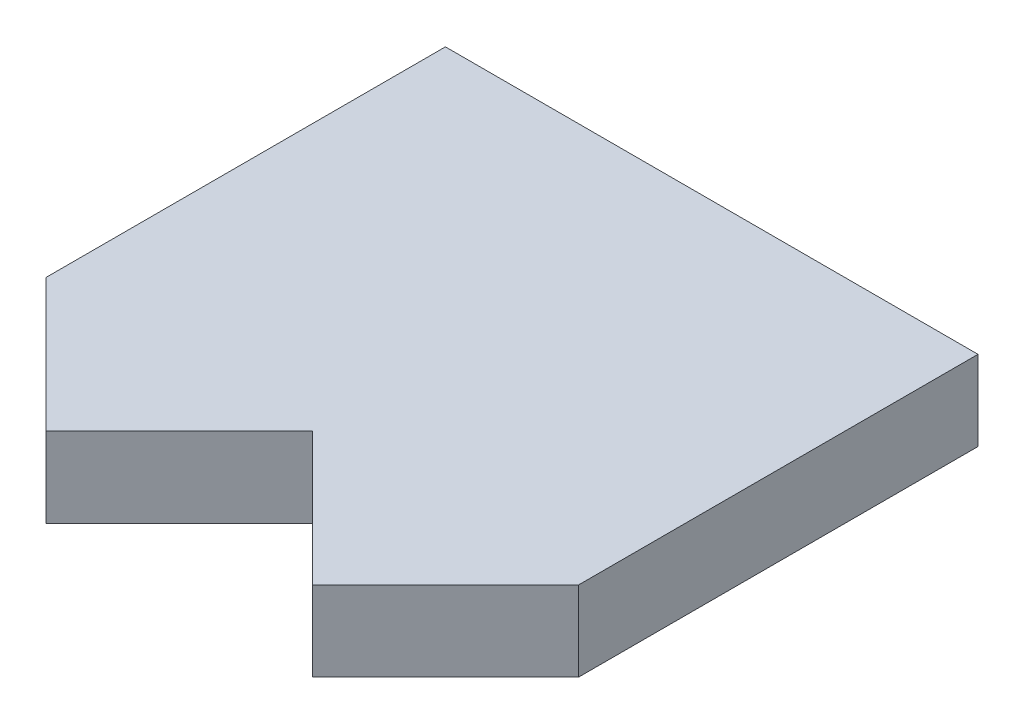
from build123d import *

# Parameters (mm, degrees)
SKETCH1_W               = 20
SKETCH1_H               = 20
BOSS_EXTRUDE1_DEPTH     = 3
CUT_EXTRUDE1_DEPTH      = 1
CUT_EXTRUDE1_DEPTH_BACK = 4


with BuildPart() as part:
    # Sketch1 → Boss-Extrude1 (new body)
    with BuildSketch(Plane(origin=(0, 0, 0), x_dir=(1, 0, 0), z_dir=(0, 1, 0))):
        Rectangle(SKETCH1_W, SKETCH1_H)
    extrude(amount=BOSS_EXTRUDE1_DEPTH)

    # Sketch2 → Cut-Extrude1 (cut, two sides)
    with BuildSketch(Plane(origin=(0, 3, 0), x_dir=(1, 0, 0), z_dir=(0, 1, 0))) as cut_extrude1_sk:
        Polygon((-5, -10), (-10, -5), (-10, -10), align=None)
        Polygon((0, -5), (-5, -10), (5, -10), align=None)
        Polygon((10, -5), (5, -10), (10, -10), align=None)
    extrude(amount=CUT_EXTRUDE1_DEPTH, mode=Mode.SUBTRACT)
    extrude(cut_extrude1_sk.sketch, amount=-CUT_EXTRUDE1_DEPTH_BACK, mode=Mode.SUBTRACT)


solid = part.part
